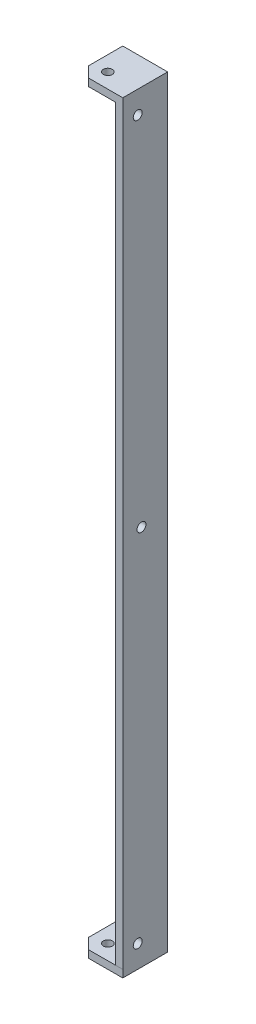
from build123d import *

# Parameters (mm, degrees)
SKETCH1_W           = 25
SKETCH1_H           = 500
SKETCH1_R           = 3
BOSS_EXTRUDE1_DEPTH = 5
SKETCH2_W           = 5
SKETCH2_H           = 500
BOSS_EXTRUDE2_DEPTH = 30
SKETCH3_R           = 3
CUT_EXTRUDE1_DEPTH  = 20.5
SKETCH4_R           = 3
BOSS_EXTRUDE3_DEPTH = 5
SKETCH5_R           = 3
BOSS_EXTRUDE4_DEPTH = 5


with BuildPart() as part:
    # Sketch1 → Boss-Extrude1 (new body)
    with BuildSketch(Plane.XY):
        Rectangle(SKETCH1_W, SKETCH1_H)
        with Locations((-2.5, 240)):
            Circle(SKETCH1_R, mode=Mode.SUBTRACT)
        with Locations((-2.5, -240)):
            Circle(SKETCH1_R, mode=Mode.SUBTRACT)
        Circle(SKETCH1_R, mode=Mode.SUBTRACT)
    extrude(amount=BOSS_EXTRUDE1_DEPTH)

    # Sketch2 → Boss-Extrude2 (add)
    with BuildSketch(Plane(origin=(0, 0, 0), x_dir=(-1, 0, 0), z_dir=(0, 0, -1))):
        with Locations((-15, 0)):
            Rectangle(SKETCH2_W, SKETCH2_H)
    extrude(amount=-BOSS_EXTRUDE2_DEPTH)

    # Sketch3 → Cut-Extrude1 (cut)
    with BuildSketch(Plane.ZY.offset(-12.5)):
        with Locations((20, -240)):
            Circle(SKETCH3_R)
        with Locations((17.5, 0)):
            Circle(SKETCH3_R)
        with Locations((20, 240)):
            Circle(SKETCH3_R)
    extrude(amount=-CUT_EXTRUDE1_DEPTH, mode=Mode.SUBTRACT)

    # Sketch4 → Boss-Extrude3 (add)
    with BuildSketch(Plane(origin=(0, 250, 0), x_dir=(1, 0, 0), z_dir=(0, 1, 0))):
        Polygon((-12.5, 0), (17.5, 0), (17.5, -30), (-5.428932188, -30), (-12.5, -22.928932188), align=None)
        with Locations((-2.5, -20)):
            Circle(SKETCH4_R, mode=Mode.SUBTRACT)
    extrude(amount=BOSS_EXTRUDE3_DEPTH)

    # Sketch5 → Boss-Extrude4 (add)
    with BuildSketch(Plane(origin=(0, -250, 0), x_dir=(-1, 0, 0), z_dir=(0, -1, 0))):
        Polygon((12.5, 0), (-17.5, 0), (-17.5, -30), (5.456313249, -30.054721724), (12.5, -22.95637847), align=None)
        with Locations((2.5, -20)):
            Circle(SKETCH5_R, mode=Mode.SUBTRACT)
    extrude(amount=BOSS_EXTRUDE4_DEPTH)


solid = part.part
